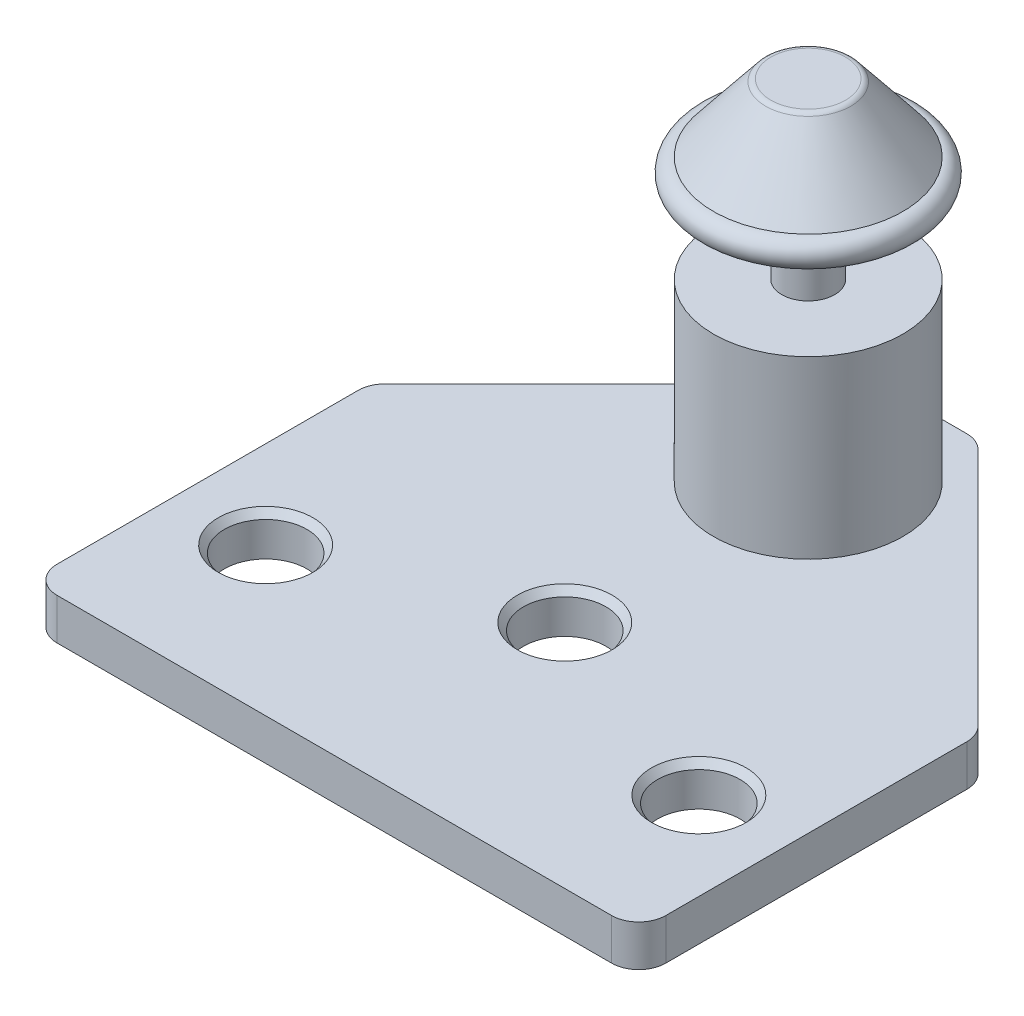
from build123d import *

# Parameters (mm, degrees)
EXTRUDE1_DEPTH   = 3.048
HOLE1_AT_2_COUNT = 2
HOLE1_AT_2_PITCH = 17.121951291
HOLE1_AT_3_COUNT = 2
HOLE1_AT_3_PITCH = 17.121951291
SKETCH4_R        = 7
EXTRUDE2_DEPTH   = 12.954
SKETCH5_R        = 1.9558
EXTRUDE3_DEPTH   = 5.842
SKETCH6_R        = 1.5
EXTRUDE4_DEPTH   = 1.4
SKETCH7_R        = 1.9558
EXTRUDE6_DEPTH   = 3.1
FILLET1_R        = 0.5
FILLET2_R        = 2


with BuildPart() as part:
    # Sketch1 → Extrude1 (new body)
    with BuildSketch(Plane(origin=(0, 0, 0), x_dir=(1, 0, 0), z_dir=(0, 1, 0))):
        Polygon((-22.479, -25.063), (-22.479, 0), (-3.6, 18.879), (3.6, 18.879), (22.479, 0), (22.479, -25.063), align=None)
    extrude(amount=EXTRUDE1_DEPTH)

    # Sketch2 → Hole1 (revolve, cut)
    with BuildSketch(Plane(origin=(0, 3.048, 8.045), x_dir=(0, 0, 1), z_dir=(1, 0, 0))):
        Polygon((0, 0), (0, 3.048), (3.048, 3.048), (3.048, 0.51996652), (3.5, 0), align=None)
    hole1 = revolve(axis=Axis((0, 9.493314094, 8.045), (0, -1, 0)), mode=Mode.SUBTRACT)

    # Hole1 at 2: Hole1 ×2
    with Locations(*[Vector(0.934472931, 0, 0.356034187) * (i * HOLE1_AT_2_PITCH) for i in range(1, HOLE1_AT_2_COUNT)]):
        add(hole1, mode=Mode.SUBTRACT)

    # Hole1 at 3: Hole1 ×2
    with Locations(*[Vector(-0.934472931, 0, 0.356034187) * (i * HOLE1_AT_3_PITCH) for i in range(1, HOLE1_AT_3_COUNT)]):
        add(hole1, mode=Mode.SUBTRACT)

    # Sketch4 → Extrude2 (add)
    with BuildSketch(Plane(origin=(0, 3.048, 0), x_dir=(-1, 0, 0), z_dir=(0, 1, 0))):
        with Locations((0, -9.937)):
            Circle(SKETCH4_R)
    extrude(amount=EXTRUDE2_DEPTH)

    # Sketch5 → Extrude3 (add)
    with BuildSketch(Plane(origin=(0, 16.002, 0), x_dir=(-1, 0, 0), z_dir=(0, 1, 0))):
        with Locations((0, -9.937)):
            Circle(SKETCH5_R)
    extrude(amount=EXTRUDE3_DEPTH)

    # Sketch6 → Extrude4 (add)
    with BuildSketch(Plane(origin=(0, 21.844, 0), x_dir=(-1, 0, 0), z_dir=(0, 1, 0))):
        with Locations((0, -9.937)):
            Circle(SKETCH6_R)
    extrude(amount=EXTRUDE4_DEPTH)

    # Sketch7 → Extrude6 (add)
    with BuildSketch(Plane(origin=(0, 23.244, 0), x_dir=(-1, 0, 0), z_dir=(0, 1, 0))):
        with Locations((0, -9.937)):
            Circle(SKETCH7_R)
    extrude(amount=EXTRUDE6_DEPTH)

    # Fillet2
    fillet2_edges = [part.edges().sort_by_distance(p)[0] for p in [
        (-22.479, 1.524, 25.063),
        (-22.479, 1.524, 0),
        (-3.6, 1.524, -18.879),
        (3.6, 1.524, -18.879),
        (22.479, 1.524, 0),
        (22.479, 1.524, 25.063),
    ]]
    fillet(fillet2_edges, radius=FILLET2_R)


with BuildPart() as body_2:
    # Sketch8 → Revolve1 (revolve)
    with BuildSketch(Plane.XY.offset(-9.937)):
        with BuildLine():
            Line((7, 23.844), (3, 28.844))
            Line((3, 28.844), (0, 28.844))
            Line((0, 28.844), (0, 26.494))
            Line((0, 26.494), (2.0558, 26.494))
            Line((2.0558, 26.494), (2.0558, 21.844))
            Line((2.0558, 21.844), (7, 21.844))
            ThreePointArc((7, 21.844), (8, 22.844), (7, 23.844))
        make_face()
    revolve(axis=Axis((0, 21.844, -9.937), (0, -1, 0)))

    # Fillet1
    fillet1_edges = [body_2.edges().sort_by_distance(p)[0] for p in [
        (-3, 28.844, -9.937),
    ]]
    fillet(fillet1_edges, radius=FILLET1_R)


solid = Compound([part.part, body_2.part])
